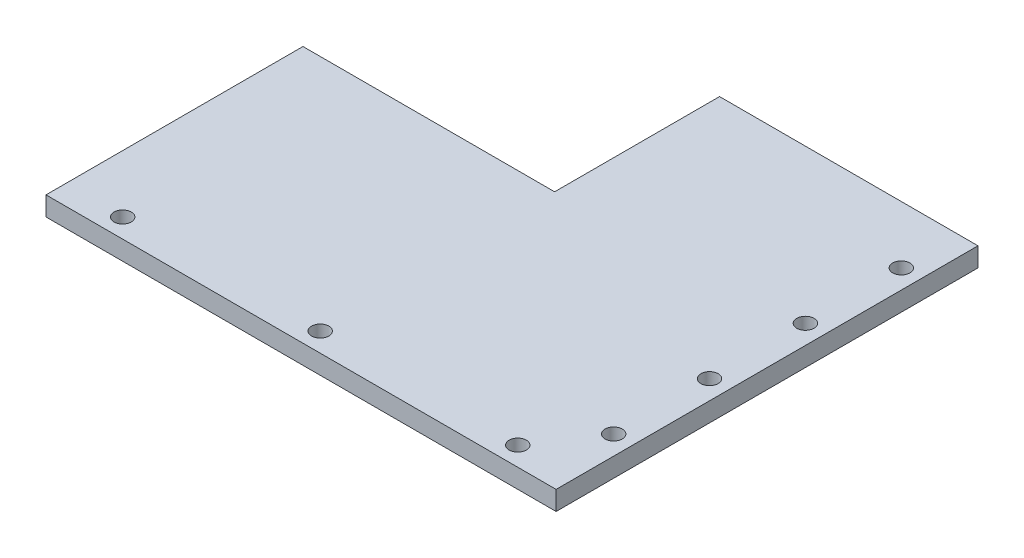
from build123d import *

# Parameters (mm, degrees)
SKETCH1_R           = 2.25
BOSS_EXTRUDE1_DEPTH = 5


with BuildPart() as part:
    # Sketch1 → Boss-Extrude1 (new body)
    with BuildSketch(Plane(origin=(0, 0, 0), x_dir=(1, 0, 0), z_dir=(0, 1, 0))):
        Polygon((0, 55.733260811), (0, 12.733260811), (-65.613421019, 12.733260811), (-65.613421019, -54.266739189), (67.386578981, -54.266739189), (67.386578981, 55.733260811), align=None)
        with Locations((62.386578981, 40.733260811)):
            Circle(SKETCH1_R, mode=Mode.SUBTRACT)
        with Locations((62.386578981, 15.733260811)):
            Circle(SKETCH1_R, mode=Mode.SUBTRACT)
        with Locations((62.386578981, -9.266739189)):
            Circle(SKETCH1_R, mode=Mode.SUBTRACT)
        with Locations((62.386578981, -34.266739189)):
            Circle(SKETCH1_R, mode=Mode.SUBTRACT)
        with Locations((0.886578981, -49.266739189)):
            Circle(SKETCH1_R, mode=Mode.SUBTRACT)
        with Locations((-50.613421019, -49.266739189)):
            Circle(SKETCH1_R, mode=Mode.SUBTRACT)
        with Locations((52.386578981, -49.266739189)):
            Circle(SKETCH1_R, mode=Mode.SUBTRACT)
    extrude(amount=BOSS_EXTRUDE1_DEPTH)


solid = part.part
